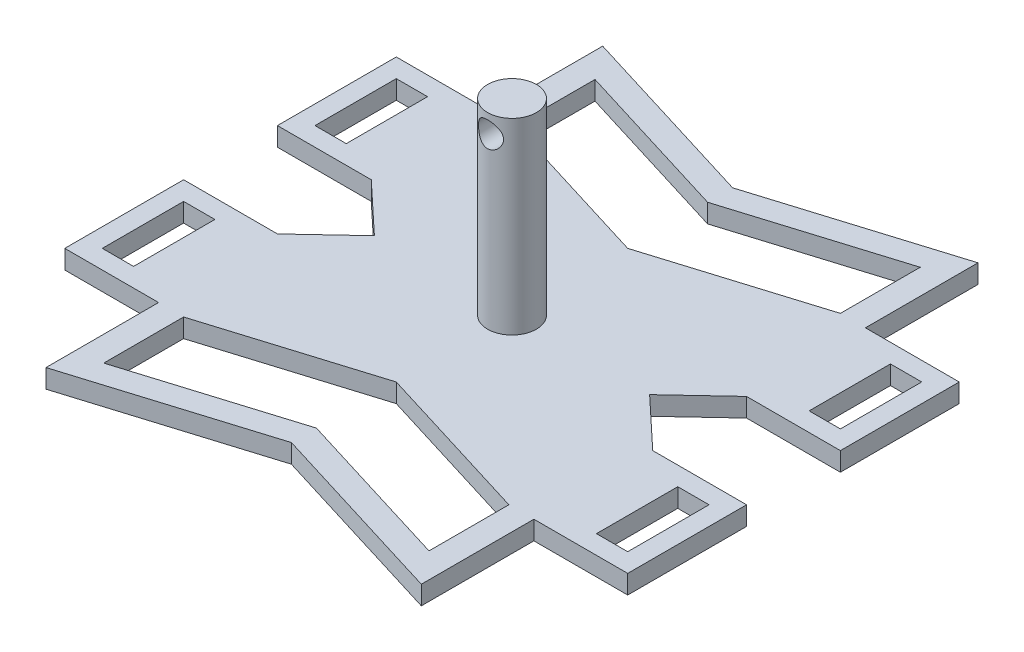
from build123d import *

# Parameters (mm, degrees)
CROQUIS1_W                 = 5
CROQUIS1_H                 = 13
SALIENTE_EXTRUIR1_DEPTH    = 3
CROQUIS9_R                 = 3.9
SALIENTE_EXTRUIR2_DEPTH    = 30
CROQUIS10_R                = 2
CORTAR_EXTRUIR7_DEPTH      = 45.5
CORTAR_EXTRUIR7_DEPTH_BACK = 45.5


with BuildPart() as part:
    # Croquis1 → Saliente-Extruir1 (new body)
    with BuildSketch(Plane(origin=(0, 0, 0), x_dir=(1, 0, 0), z_dir=(0, 1, 0))):
        Polygon((-45, -26.5), (-30, -26.5), (-30, -44.5), (0, -35.269230769), (30, -44.5), (30, -26.5), (45, -26.5), (45, -7.5), (30, -7.5), (22, 0), (30, 7.5), (45, 7.5), (45, 26.5), (30, 26.5), (30, 44.5), (0, 35.269230769), (-30, 44.5), (-30, 26.5), (-45, 26.5), (-45, 7.5), (-30, 7.5), (-22, 0), (-30, -7.5), (-45, -7.5), align=None)
        Polygon((0, -18.5), (26, -26.5), (26, -39.269230769), (0, -31.269230769), (-26, -39.269230769), (-26, -26.5), align=None, mode=Mode.SUBTRACT)
        Polygon((26, 26.5), (0, 18.5), (-26, 26.5), (-26, 39.269230769), (0, 31.269230769), (26, 39.269230769), align=None, mode=Mode.SUBTRACT)
        with Locations((39.5, -17)):
            Rectangle(CROQUIS1_W, CROQUIS1_H, mode=Mode.SUBTRACT)
        with Locations((39.5, 17)):
            Rectangle(CROQUIS1_W, CROQUIS1_H, mode=Mode.SUBTRACT)
        with Locations((-39.5, 17)):
            Rectangle(CROQUIS1_W, CROQUIS1_H, mode=Mode.SUBTRACT)
        with Locations((-39.5, -17)):
            Rectangle(CROQUIS1_W, CROQUIS1_H, mode=Mode.SUBTRACT)
    extrude(amount=SALIENTE_EXTRUIR1_DEPTH)

    # Croquis9 → Saliente-Extruir2 (add)
    with BuildSketch(Plane(origin=(0, 3, 0), x_dir=(1, 0, 0), z_dir=(0, 1, 0))):
        Circle(CROQUIS9_R)
    extrude(amount=SALIENTE_EXTRUIR2_DEPTH)

    # Croquis10 → Cortar-Extruir7 (cut, two sides)
    with BuildSketch(Plane.XY) as cortar_extruir7_sk:
        with Locations((0, 30)):
            Circle(CROQUIS10_R)
    extrude(amount=CORTAR_EXTRUIR7_DEPTH, mode=Mode.SUBTRACT)
    extrude(cortar_extruir7_sk.sketch, amount=-CORTAR_EXTRUIR7_DEPTH_BACK, mode=Mode.SUBTRACT)


solid = part.part
